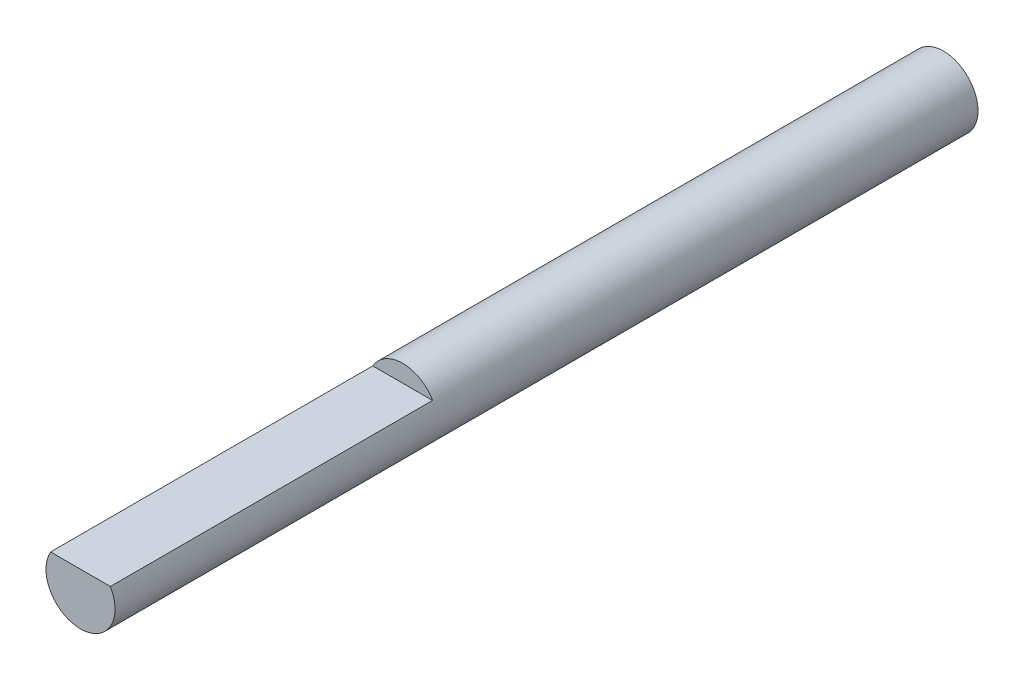
from build123d import *

# Parameters (mm, degrees)
SKETCH2_R           = 6
BOSS_EXTRUDE1_DEPTH = 150
CUT_EXTRUDE1_DEPTH  = 56


with BuildPart() as part:
    # Sketch2 → Boss-Extrude1 (new body)
    with BuildSketch(Plane.XY):
        Circle(SKETCH2_R)
    extrude(amount=BOSS_EXTRUDE1_DEPTH)

    # Sketch3 → Cut-Extrude1 (cut)
    with BuildSketch(Plane.XY.offset(150)):
        with BuildLine():
            ThreePointArc((5.196152423, 3), (0, 6), (-5.196152423, 3))
            Line((-5.196152423, 3), (5.196152423, 3))
        make_face()
    extrude(amount=-CUT_EXTRUDE1_DEPTH, mode=Mode.SUBTRACT)


solid = part.part
